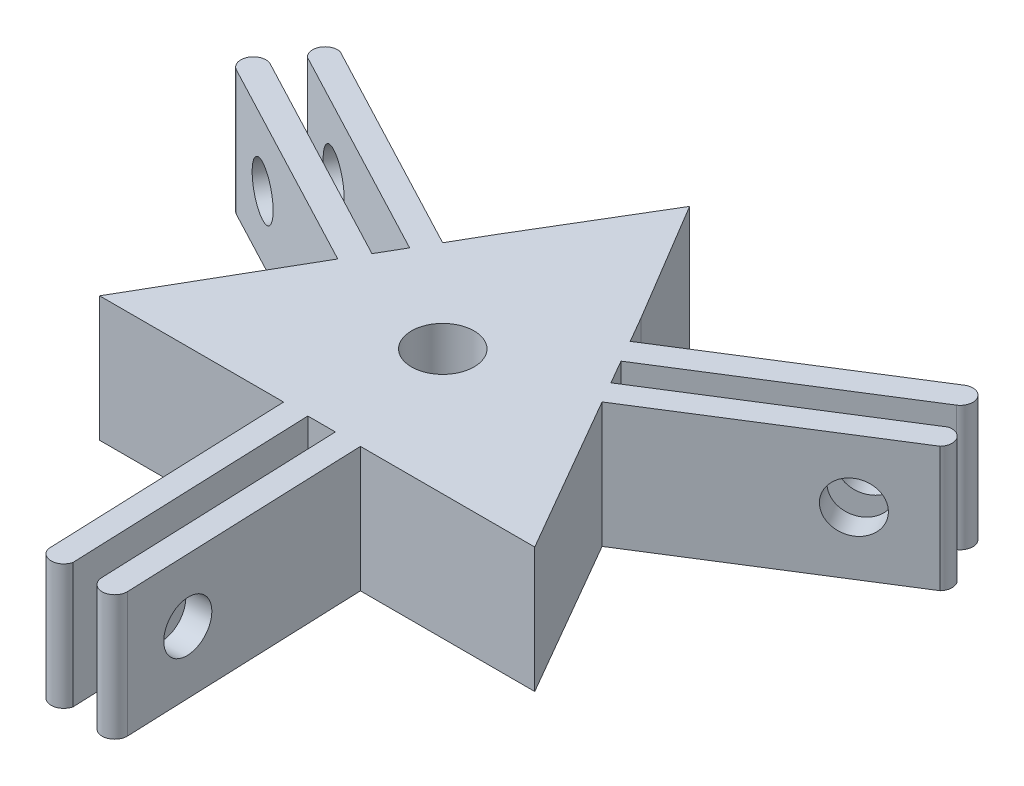
from build123d import *

# Parameters (mm, degrees)
SKETCH1_R           = 2.5
BOSS_EXTRUDE1_DEPTH = 10
SKETCH2_R           = 2
CUT_EXTRUDE1_DEPTH  = 10
CIRPATTERN1_COUNT   = 3
SKETCH3_R           = 2.5
BOSS_EXTRUDE3_DEPTH = 10
SKETCH4_R           = 2.500796224
BOSS_EXTRUDE4_DEPTH = 10


with BuildPart() as part:
    # Sketch1 → Boss-Extrude1 (new body)
    with BuildSketch(Plane(origin=(0, 0, 0), x_dir=(1, 0, 0), z_dir=(0, 1, 0))):
        with BuildLine():
            Line((3.42943918, -9.393558799), (4.197898245, -29.378790113))
            ThreePointArc((4.197898245, -29.378790113), (3.237059632, -30.416474632), (2.199375114, -29.455636019))
            Line((2.199375114, -29.455636019), (1.447231615, -9.894721858))
            ThreePointArc((1.447231615, -9.894721858), (0.350023332, -9.993872306), (-0.751433173, -9.971727442))
            Line((-0.751433173, -9.971727442), (0.000999669, -29.540166516))
            ThreePointArc((0.000999669, -29.540166516), (-0.935779597, -30.318112399), (-1.929530696, -29.614398009))
            Line((-1.929530696, -29.614398009), (-2.697989761, -9.629166695))
            ThreePointArc((-2.697989761, -9.629166695), (-8.461744243, -5.329060364), (-9.849780142, 1.726797949))
            Line((-9.849780142, 1.726797949), (-27.541727692, 11.053908534))
            ThreePointArc((-27.541727692, 11.053908534), (-27.959969541, 12.404861441), (-26.609016634, 12.823103289))
            Line((-26.609016634, 12.823103289), (-9.2926963, 3.694021585))
            ThreePointArc((-9.2926963, 3.694021585), (-8.829958965, 4.693807055), (-8.260052699, 5.636623938))
            Line((-8.260052699, 5.636623938), (-25.58303447, 14.769217519))
            ThreePointArc((-25.58303447, 14.769217519), (-25.788365734, 15.969465103), (-24.682055646, 16.478221605))
            Line((-24.682055646, 16.478221605), (-6.990108095, 7.15111102))
            ThreePointArc((-6.990108095, 7.15111102), (-0.384229532, 9.992615657), (6.420340962, 7.66676085))
            Line((6.420340962, 7.66676085), (23.343829448, 18.324881579))
            ThreePointArc((23.343829448, 18.324881579), (24.722909908, 18.011613191), (24.40964152, 16.63253273))
            Line((24.40964152, 16.63253273), (7.845464685, 6.200700273))
            ThreePointArc((7.845464685, 6.200700273), (8.479935633, 5.300065251), (9.011485871, 4.335103505))
            Line((9.011485871, 4.335103505), (25.582034801, 14.770948997))
            ThreePointArc((25.582034801, 14.770948997), (26.724145331, 14.348647296), (26.611586342, 13.136176404))
            Line((26.611586342, 13.136176404), (9.688097856, 2.478055676))
            ThreePointArc((9.688097856, 2.478055676), (8.845973775, -4.663555293), (3.42943918, -9.393558799))
        make_face()
        Circle(SKETCH1_R, mode=Mode.SUBTRACT)
    extrude(amount=BOSS_EXTRUDE1_DEPTH)

    # Sketch2 → Cut-Extrude1 (cut)
    with BuildSketch(Plane(origin=(3.063714471, 0, -0.117803948), x_dir=(-0.038422953, 0, -0.999261566), z_dir=(0.999261566, 0, -0.038422953))):
        with Locations((-24.518391454, 5)):
            Circle(SKETCH2_R)
    cut_extrude1 = extrude(amount=-CUT_EXTRUDE1_DEPTH, mode=Mode.SUBTRACT)

    # CirPattern1: Cut-Extrude1 ×3 about axis
    cirpattern1_axis = Axis((0, 10, 0), (0, -1, 0))
    for i in range(1, CIRPATTERN1_COUNT):
        add(cut_extrude1.rotate(cirpattern1_axis, i * 360 / CIRPATTERN1_COUNT), mode=Mode.SUBTRACT)

    # Sketch3 → Boss-Extrude3 (add)
    with BuildSketch(Plane(origin=(0, 10, 0), x_dir=(1, 0, 0), z_dir=(0, 1, 0))):
        Polygon((11.5901527, 0), (5.79507635, 10.037366672), (-5.79507635, 10.037366672), (-11.5901527, 0), (-5.79507635, -10.037366672), (5.79507635, -10.037366672), align=None)
        Circle(SKETCH3_R, mode=Mode.SUBTRACT)
    extrude(amount=-BOSS_EXTRUDE3_DEPTH)

    # Sketch4 → Boss-Extrude4 (add)
    with BuildSketch(Plane(origin=(0, 10, 0), x_dir=(1, 0, 0), z_dir=(0, 1, 0))):
        Polygon((-5.79507635, 10.037366672), (0, 19.724396452), (5.79507635, 10.037366672), (11.5901527, 0), (17.38522905, -10.037366672), (5.79507635, -10.037366672), (-5.79507635, -10.037366672), (-17.38522905, -10.037366672), (-11.5901527, 0), align=None)
        Circle(SKETCH4_R, mode=Mode.SUBTRACT)
    extrude(amount=-BOSS_EXTRUDE4_DEPTH)


solid = part.part
